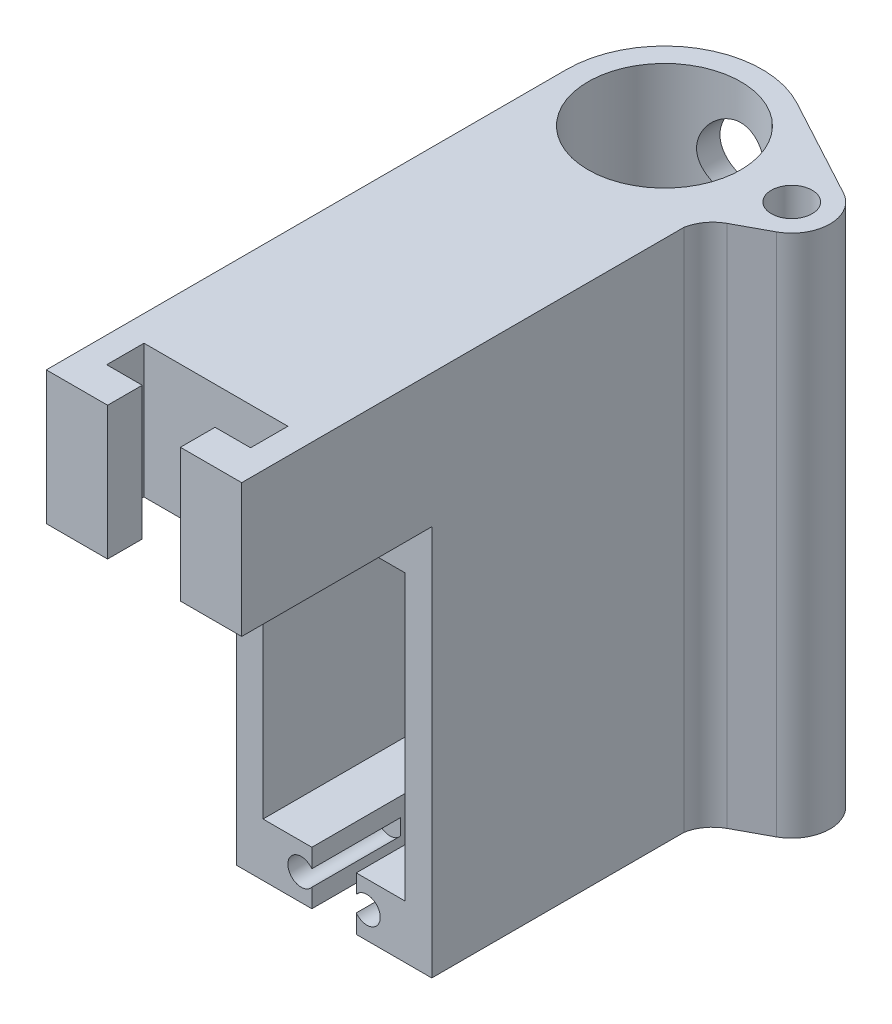
from build123d import *

# Parameters (mm, degrees)
SKETCH2_W             = 20.32
SKETCH2_H             = 7.62
SKETCH2_R             = 1.905
BOSS_EXTRUDE1_DEPTH   = 12.7
BOSS_EXTRUDE1_2_DEPTH = 12.7
SKETCH4_W             = 3.81
SKETCH4_H             = 55.88
BOSS_EXTRUDE2_DEPTH   = 28.702
SKETCH5_W             = 27.94
SKETCH5_H             = 55.88
BOSS_EXTRUDE3_DEPTH   = 7.62
SKETCH6_R             = 10.922
BOSS_EXTRUDE6_DEPTH   = 55.88
SKETCH10_W            = 20.32
SKETCH10_H            = 16.002
BOSS_EXTRUDE7_DEPTH   = 7.62
SKETCH11_W            = 20.32
SKETCH11_H            = 16.002
BOSS_EXTRUDE8_DEPTH   = 7.62
SKETCH12_R            = 10.922
BOSS_EXTRUDE9_DEPTH   = 19.05
SKETCH14_R            = 2.921
BOSS_EXTRUDE10_DEPTH  = 74.93
SKETCH17_R            = 5.08
CUT_EXTRUDE3_DEPTH    = 32.766
SKETCH18_W            = 6.35
SKETCH18_H            = 7.62
CUT_EXTRUDE4_DEPTH    = 28.702


with BuildPart() as part:
    # Sketch2 → Boss-Extrude1 (new body)
    with BuildSketch(Plane.XY):
        with Locations((0, 24.13)):
            Rectangle(SKETCH2_W, SKETCH2_H)
        with Locations((4.699, 24.13)):
            Circle(SKETCH2_R, mode=Mode.SUBTRACT)
        with Locations((-4.699, 24.13)):
            Circle(SKETCH2_R, mode=Mode.SUBTRACT)
    extrude(amount=BOSS_EXTRUDE1_DEPTH)



with BuildPart() as body_2:
    # Sketch2 → Boss-Extrude1 2 (new body)
    with BuildSketch(Plane.XY):
        with Locations((0, -24.13)):
            Rectangle(SKETCH2_W, SKETCH2_H)
        with Locations((-4.699, -24.13)):
            Circle(SKETCH2_R, mode=Mode.SUBTRACT)
        with Locations((4.699, -24.13)):
            Circle(SKETCH2_R, mode=Mode.SUBTRACT)
    extrude(amount=BOSS_EXTRUDE1_2_DEPTH)


with BuildPart() as part_1:
    add(part.part)

    add(body_2.part)  # Boss-Extrude2 merges body 2
    # Sketch4 → Boss-Extrude2 (add)
    with BuildSketch(Plane.XY.offset(12.7)):
        with Locations((-12.065, 0)):
            Rectangle(SKETCH4_W, SKETCH4_H)
        with Locations((12.065, 0)):
            Rectangle(SKETCH4_W, SKETCH4_H)
    extrude(amount=-BOSS_EXTRUDE2_DEPTH)

    # Sketch5 → Boss-Extrude3 (add)
    with BuildSketch(Plane(origin=(0, 0, -16.002), x_dir=(-1, 0, 0), z_dir=(0, 0, -1))):
        Rectangle(SKETCH5_W, SKETCH5_H)
    extrude(amount=BOSS_EXTRUDE3_DEPTH)

    # Sketch6 → Boss-Extrude6 (add)
    with BuildSketch(Plane(origin=(0, 27.94, 0), x_dir=(1, 0, 0), z_dir=(0, 1, 0))):
        with BuildLine():
            Line((8.710385525, 23.622), (13.97, 23.622))
            Line((13.97, 23.622), (13.97, 34.544))
            ThreePointArc((13.97, 34.544), (0, 48.514), (-13.97, 34.544))
            Line((-13.97, 34.544), (-13.97, 23.622))
            Line((-13.97, 23.622), (-8.710385525, 23.622))
            ThreePointArc((-8.710385525, 23.622), (0, 20.574), (8.710385525, 23.622))
        make_face()
        with Locations((0, 34.544)):
            Circle(SKETCH6_R, mode=Mode.SUBTRACT)
    extrude(amount=-BOSS_EXTRUDE6_DEPTH)

    # Sketch10 → Boss-Extrude7 (add)
    with BuildSketch(Plane(origin=(0, 27.94, 0), x_dir=(1, 0, 0), z_dir=(0, 1, 0))):
        with Locations((0, 8.001)):
            Rectangle(SKETCH10_W, SKETCH10_H)
    extrude(amount=-BOSS_EXTRUDE7_DEPTH)

    # Sketch11 → Boss-Extrude8 (add)
    with BuildSketch(Plane.XZ.offset(27.94)):
        with Locations((0, -8.001)):
            Rectangle(SKETCH11_W, SKETCH11_H)
    extrude(amount=-BOSS_EXTRUDE8_DEPTH)

    # Sketch12 → Boss-Extrude9 (add)
    with BuildSketch(Plane(origin=(0, 27.94, 0), x_dir=(1, 0, 0), z_dir=(0, 1, 0))):
        Polygon((-13.97, -12.7), (-13.97, -39.878), (-5.207, -39.878), (-5.207, -34.925), (-10.287, -34.925), (-10.287, -29.591), (10.287, -29.591), (10.287, -34.925), (5.207, -34.925), (5.207, -39.878), (13.97, -39.878), (13.97, -12.7), align=None)
        with BuildLine():
            Line((13.97, -12.7), (13.97, 34.544))
            ThreePointArc((13.97, 34.544), (0, 48.514), (-13.97, 34.544))
            Line((-13.97, 34.544), (-13.97, -12.7))
            Line((-13.97, -12.7), (13.97, -12.7))
        make_face()
        with Locations((0, 34.544)):
            Circle(SKETCH12_R, mode=Mode.SUBTRACT)
    extrude(amount=BOSS_EXTRUDE9_DEPTH)

    # Sketch14 → Boss-Extrude10 (add)
    with BuildSketch(Plane(origin=(0, 46.99, 0), x_dir=(1, 0, 0), z_dir=(0, 1, 0))):
        with BuildLine():
            Line((21.132926123, 39.011999157), (6.635812906, 46.837367605))
            ThreePointArc((6.635812906, 46.837367605), (11.997149793, 41.701464415), (13.97, 34.544))
            Line((13.97, 34.544), (13.97, 26.397222721))
            Line((13.97, 26.397222721), (13.97, 23.366509606))
            ThreePointArc((13.97, 23.366509606), (14.856612526, 25.442827777), (16.555367234, 26.929909268))
            Line((16.555367234, 26.929909268), (21.132926123, 29.400820847))
            ThreePointArc((21.132926123, 29.400820847), (23.999926533, 34.206410002), (21.132926123, 39.011999157))
        make_face()
        with Locations((18.538926533, 34.206410002)):
            Circle(SKETCH14_R, mode=Mode.SUBTRACT)
    extrude(amount=-BOSS_EXTRUDE10_DEPTH)

    # Sketch17 → Cut-Extrude3 (cut)
    with BuildSketch(Plane(origin=(0, 0, -48.514), x_dir=(-1, 0, 0), z_dir=(0, 0, -1))):
        with Locations((0, 36.83)):
            Circle(SKETCH17_R)
    extrude(amount=-CUT_EXTRUDE3_DEPTH, mode=Mode.SUBTRACT)

    # Sketch18 → Cut-Extrude4 (cut)
    with BuildSketch(Plane.XY.offset(12.7)):
        with Locations((0, -24.13)):
            Rectangle(SKETCH18_W, SKETCH18_H)
    extrude(amount=-CUT_EXTRUDE4_DEPTH, mode=Mode.SUBTRACT)


solid = part_1.part
